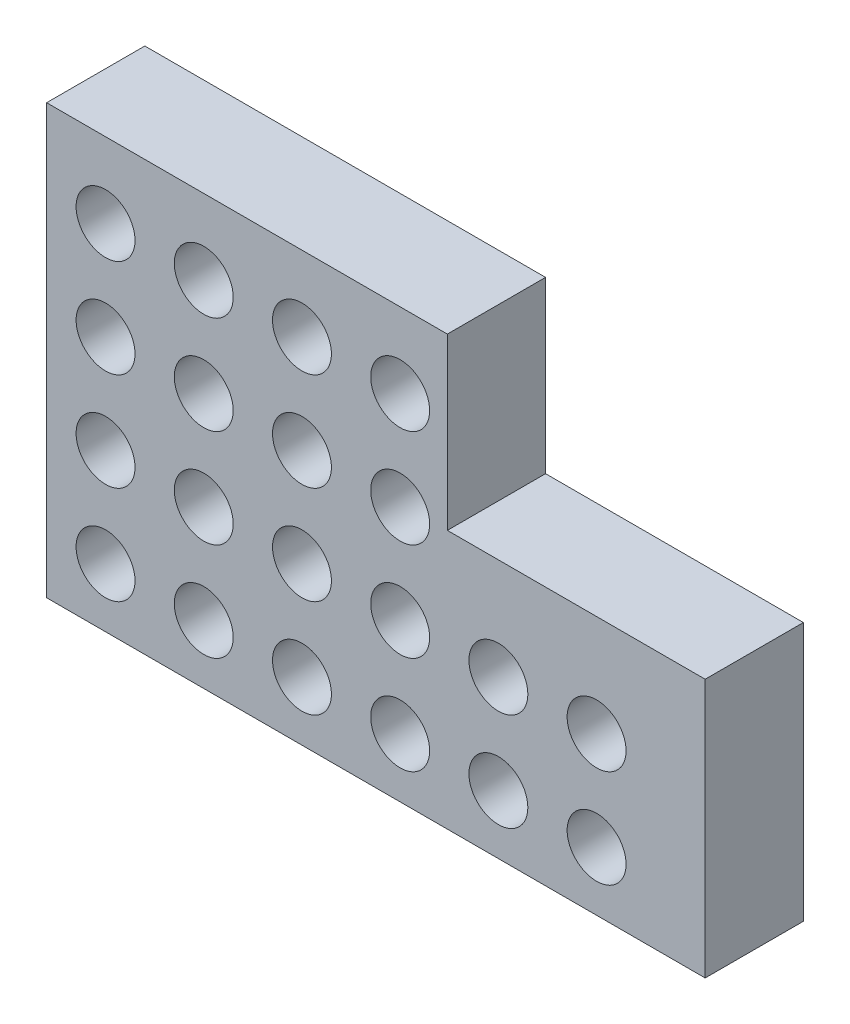
from build123d import *

# Parameters (mm, degrees)
BOSS_EXTRUDE1_DEPTH  = 10
SKETCH2_R            = 3
CUT_EXTRUDE1_DEPTH   = 10
LPATTERN1_COUNT      = 6
LPATTERN1_PITCH      = 10
LPATTERN1_COUNT_DIR2 = 4
LPATTERN1_PITCH_DIR2 = 10


with BuildPart() as part:
    # Sketch1 → Boss-Extrude1 (new body)
    with BuildSketch(Plane.XY):
        Polygon((0, 0), (0, 43.65799141), (40.804527919, 43.65799141), (40.804527919, 26.346979566), (67.056392035, 26.346979566), (67.056392035, 4.280195236), (67.056392035, 0), align=None)
    extrude(amount=BOSS_EXTRUDE1_DEPTH)

    # Sketch2 → Cut-Extrude1 (cut)
    with BuildSketch(Plane.XY.offset(10)):
        with Locations((6, 6)):
            Circle(SKETCH2_R)
    cut_extrude1 = extrude(amount=-CUT_EXTRUDE1_DEPTH, mode=Mode.SUBTRACT)

    # LPattern1: Cut-Extrude1 6 × 4, 4 skipped
    with Locations(*[(i * LPATTERN1_PITCH, j * LPATTERN1_PITCH_DIR2, 0) for i in range(LPATTERN1_COUNT) for j in range(LPATTERN1_COUNT_DIR2) if (i, j) not in ((0, 0), (4, 2), (4, 3), (5, 2), (5, 3))]):
        add(cut_extrude1, mode=Mode.SUBTRACT)


solid = part.part
